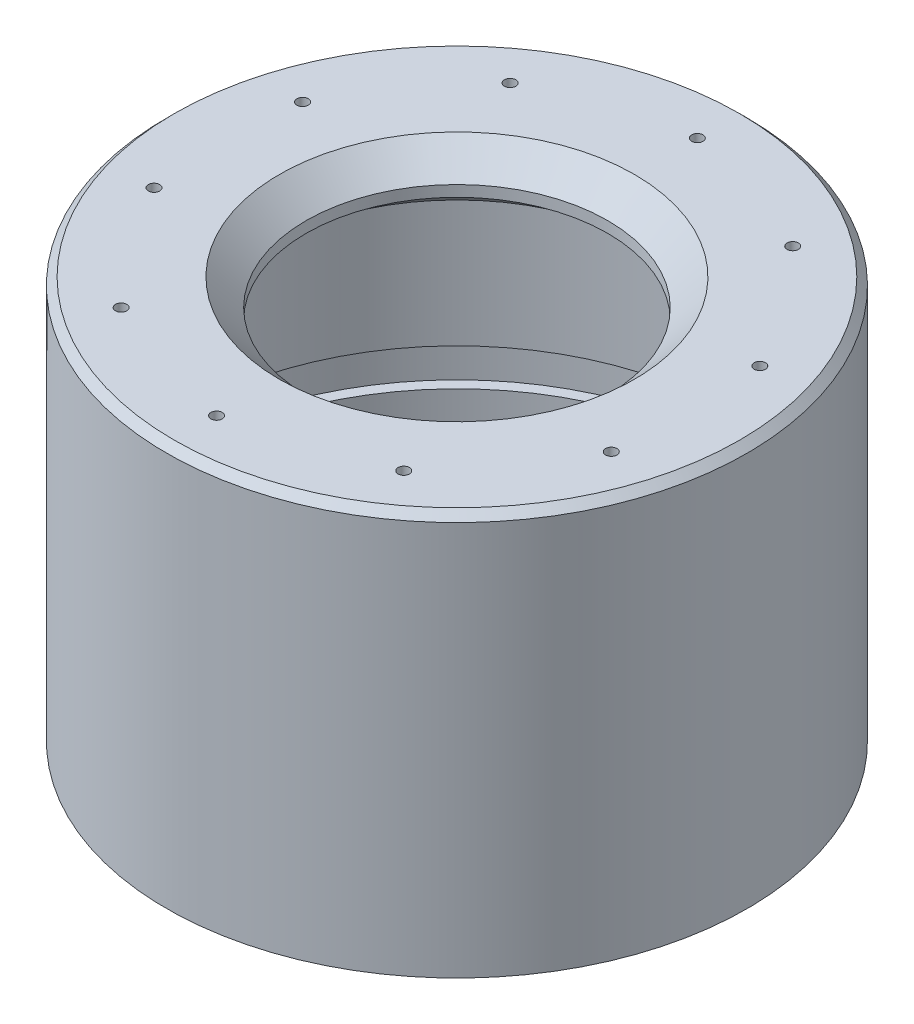
from build123d import *

# Parameters (mm, degrees)
SKETCH_2_R               = 1.5
CUT_EXTRUDE_1_DEPTH      = 184.144951188
SKETCH_2_3_R             = 3
SKETCH_2_3_R_2           = 1.5
CUT_EXTRUDE_2_DEPTH      = 3
PATTERN_CIRCULAR_1_COUNT = 10
CHAMFER_1_SIZE           = 2


with BuildPart() as part:
    # 스케치1 → 회전1 (revolve)
    with BuildSketch(Plane.XY):
        Polygon((18.23409983, 96.6), (16.31211603, 96.6), (7.79621586, 88.6), (3.23409983, 88.6), (3.23409983, 96.6), (-13.75, 96.6), (-13.75, 39.865515574), (-16.661143686, 39.865515574), (-16.661143686, 30), (-13.75, 30), (-13.75, 0), (-18.75, 0), (-18.75, 101.69494665), (-18.75, 106.6), (11.163032018, 106.6), (18.23409983, 99.528932188), align=None)
    revolve(axis=Axis((58.23409983, 90.171963423, 0), (0, 1, 0)))

    # 스케치2 → 컷-돌출1 (cut, through all)
    with BuildSketch(Plane.XZ.offset(-96.6)):
        with Locations((58.23409983, 63.75)):
            Circle(SKETCH_2_R)
    cut_extrude_1 = extrude(amount=-CUT_EXTRUDE_1_DEPTH, mode=Mode.SUBTRACT)

    # 스케치2<3> → 컷-돌출2 (cut)
    with BuildSketch(Plane.XZ.offset(-96.6)):
        with Locations((58.23409983, 63.75)):
            Circle(SKETCH_2_3_R)
        with Locations((58.23409983, 63.75)):
            Circle(SKETCH_2_3_R_2, mode=Mode.SUBTRACT)
    cut_extrude_2 = extrude(amount=-CUT_EXTRUDE_2_DEPTH, mode=Mode.SUBTRACT)

    # 원형 패턴1: 컷-돌출1, 컷-돌출2 ×10 about axis
    pattern_circular_1_axis = Axis((58.23409983, 106.6, 0), (0, -1, 0))
    add([cut_extrude_1.rotate(pattern_circular_1_axis, i * 360 / PATTERN_CIRCULAR_1_COUNT) for i in range(1, PATTERN_CIRCULAR_1_COUNT)], mode=Mode.SUBTRACT)
    add([cut_extrude_2.rotate(pattern_circular_1_axis, i * 360 / PATTERN_CIRCULAR_1_COUNT) for i in range(1, PATTERN_CIRCULAR_1_COUNT)], mode=Mode.SUBTRACT)

    # 모따기1
    chamfer_1_edges = [part.edges().sort_by_distance(p)[0] for p in [
        (135.21819966, 106.6, 0),
    ]]
    chamfer(chamfer_1_edges, length=CHAMFER_1_SIZE)


solid = part.part
